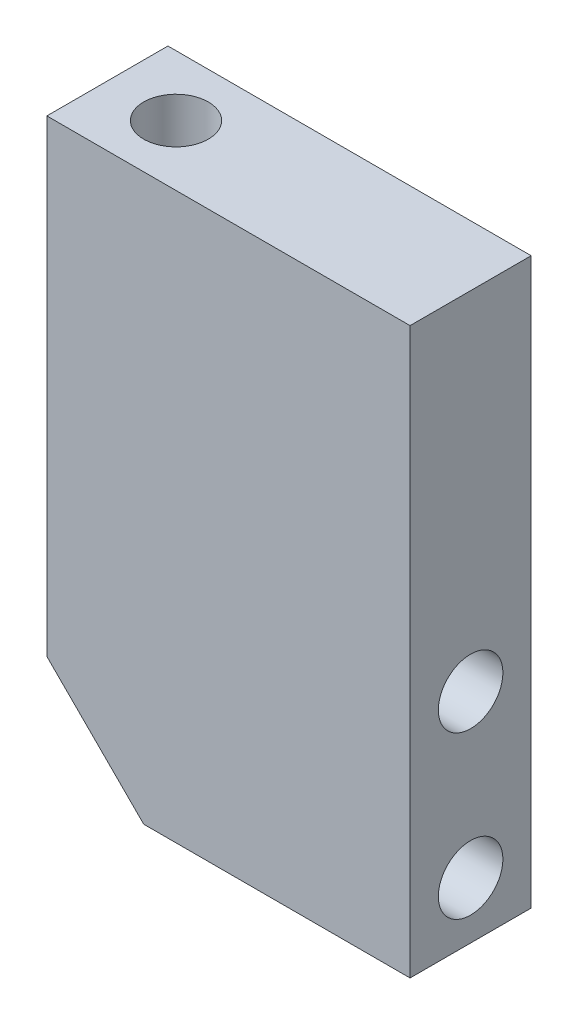
from build123d import *

# Parameters (mm, degrees)
SZKIC1_W                    = 45
SZKIC1_H                    = 70
DODANIE_WYCI_GNI_CIE1_DEPTH = 15
SZKIC3_R                    = 4
WYTNIJ_WYCI_GNI_CIE1_DEPTH  = 15
SFAZOWANIE1_SIZE            = 12
SZKIC4_R                    = 4
WYTNIJ_WYCI_GNI_CIE2_DEPTH  = 25


with BuildPart() as part:
    # Szkic1 → Dodanie-wyciągnięcie1 (new body)
    with BuildSketch(Plane.XY):
        Rectangle(SZKIC1_W, SZKIC1_H)
    extrude(amount=DODANIE_WYCI_GNI_CIE1_DEPTH)

    # Szkic3 → Wytnij-wyciągnięcie1 (cut)
    with BuildSketch(Plane(origin=(0, 35, 0), x_dir=(1, 0, 0), z_dir=(0, 1, 0))):
        with Locations((-14, -7.5)):
            Circle(SZKIC3_R)
    extrude(amount=-WYTNIJ_WYCI_GNI_CIE1_DEPTH, mode=Mode.SUBTRACT)

    # Sfazowanie1
    sfazowanie1_edges = [part.edges().sort_by_distance(p)[0] for p in [
        (-22.5, -35, 7.5),
    ]]
    chamfer(sfazowanie1_edges, length=SFAZOWANIE1_SIZE)

    # Szkic4 → Wytnij-wyciągnięcie2 (cut)
    with BuildSketch(Plane(origin=(22.5, 0, 0), x_dir=(0, 0, -1), z_dir=(1, 0, 0))):
        with Locations((-7.5, -28)):
            Circle(SZKIC4_R)
        with Locations((-7.5, -8)):
            Circle(SZKIC4_R)
    extrude(amount=-WYTNIJ_WYCI_GNI_CIE2_DEPTH, mode=Mode.SUBTRACT)


solid = part.part
